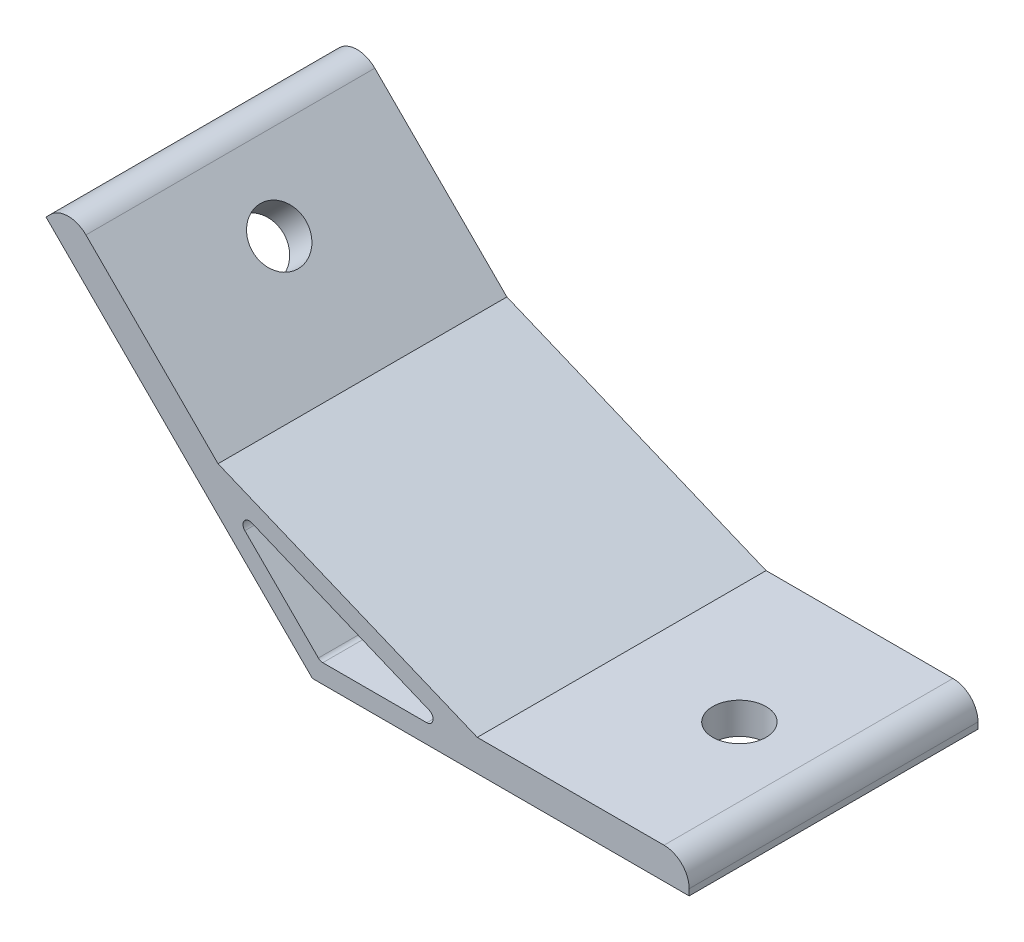
from build123d import *

# Parameters (mm, degrees)
EXTRUDE_1_DEPTH     = 23
SKETCH_2_R          = 4.25
CUT_EXTRUDE_1_DEPTH = 5
SKETCH_3_R          = 4.25
CUT_EXTRUDE_2_DEPTH = 5
FILLET_1_R          = 4
FILLET_2_R          = 1


with BuildPart() as part:
    # Эскиз1 → Бобышка-Вытянуть1 (new body, symmetric)
    with BuildSketch(Plane.XY):
        Polygon((0, 0), (-42.426406871, 42.426406871), (-38.890872965, 45.961940777), (-15.028558569, 22.099626381), (26.253591352, 5), (60, 5), (60, 0), align=None)
        Polygon((-14.313708499, 18.556349186), (23.242640687, 3), (1.242640687, 3), align=None, mode=Mode.SUBTRACT)
    extrude(amount=EXTRUDE_1_DEPTH, both=True)

    # Эскиз2 → Вырез-Вытянуть1 (cut)
    with BuildSketch(Plane(origin=(0, 0, 0), x_dir=(0, 0, 1), z_dir=(-0.707106781, -0.707106781, 0))):
        with Locations(Location((0, 45, 0), (0, 0, 270))):  # turned: the seam where the file's is
            Circle(SKETCH_2_R)
    extrude(amount=-CUT_EXTRUDE_1_DEPTH, mode=Mode.SUBTRACT)

    # Эскиз3 → Вырез-Вытянуть2 (cut)
    with BuildSketch(Plane.XZ):
        with Locations(Location((45, 0, 0), (0, 0, 270))):  # turned: the seam where the file's is
            Circle(SKETCH_3_R)
    extrude(amount=-CUT_EXTRUDE_2_DEPTH, mode=Mode.SUBTRACT)

    # Скругление1
    fillet_1_edges = [part.edges().sort_by_distance(p)[0] for p in [
        (-38.890872965, 45.961940777, 0),
        (60, 5, 0),
    ]]
    fillet(fillet_1_edges, radius=FILLET_1_R)

    # Скругление2
    fillet_2_edges = [part.edges().sort_by_distance(p)[0] for p in [
        (-14.313708499, 18.556349186, 0),
        (1.242640687, 3, 0),
        (23.242640687, 3, 0),
    ]]
    fillet(fillet_2_edges, radius=FILLET_2_R)


solid = part.part
